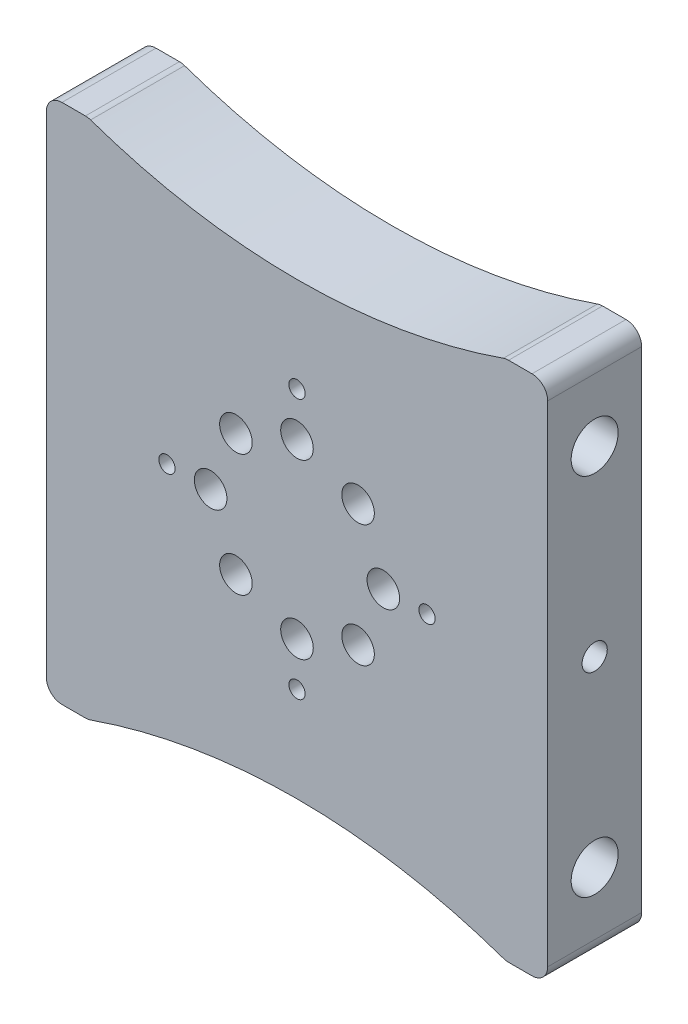
from build123d import *

# Parameters (mm, degrees)
BOSS_EXTRUDE1_DEPTH                 = 19.05
F_1_3_4_CLEARANCE_HOLE1_D           = 45
F_1_3_4_CLEARANCE_HOLE1_DEPTH       = 5
F_1_4_CLEARANCE_HOLE3_D             = 6.6
F_1_4_CLEARANCE_HOLE3_DEPTH         = 19.05
BOSS_EXTRUDE2_DEPTH                 = 19.05
SKETCH21_R                          = 30
CUT_EXTRUDE1_DEPTH                  = 20.05
BOSS_EXTRUDE5_DEPTH                 = 19.05
BOSS_EXTRUDE6_DEPTH                 = 19.05
FILLET2_R                           = 13
SKETCH29_W                          = 12.7
SKETCH29_H                          = 60
BOSS_EXTRUDE7_DEPTH                 = 19.05
BOSS_EXTRUDE8_DEPTH                 = 19.05
FILLET3_R                           = 3.175
F_3_8_0_3750_DOWEL_HOLE1_AT_2_COUNT = 2
F_3_8_0_3750_DOWEL_HOLE1_AT_2_PITCH = 73.92046334
F_4_CLEARANCE_HOLE2_D               = 3.2999934
TAP_DRILL_FOR_1_4_20_TAP1_D         = 5.1054
TAP_DRILL_FOR_1_4_20_TAP1_DEPTH     = 12.7
TAP_DRILL_FOR_1_4_20_TAP1_TIP       = 1.533816902
TAP_DRILL_FOR_1_4_20_TAP2_D         = 5.1054
TAP_DRILL_FOR_1_4_20_TAP2_DEPTH     = 12.7
TAP_DRILL_FOR_1_4_20_TAP2_TIP       = 1.533816902


with BuildPart() as part:
    # Sketch1 → Boss-Extrude1 (new body)
    with BuildSketch(Plane(origin=(0, 0, 0), x_dir=(-1, 0, 0), z_dir=(0, 0, -1))):
        with BuildLine():
            Line((44.45, 0), (44.45, 60))
            Line((44.45, 60), (-44.45, 60))
            Line((-44.45, 60), (-44.45, 0))
            ThreePointArc((-44.45, 0), (0, -44.45), (44.45, 0))
        make_face()
    extrude(amount=-BOSS_EXTRUDE1_DEPTH)

    # 1-3/4 Clearance Hole1
    with Locations(Plane(origin=(0, 0, 0), x_dir=(-1, 0, 0), z_dir=(0, 0, -1))):
        with Locations((-6, 0)):
            Hole(F_1_3_4_CLEARANCE_HOLE1_D / 2, depth=F_1_3_4_CLEARANCE_HOLE1_DEPTH)

    # 1/4 Clearance Hole3
    with Locations(Plane.XY.offset(19.05)):
        with Locations((18.374368671, 12.374368671), (23.499999956, -0.001247108), (18.374368671, -12.374368671), (6, -17.5), (-6.374368671, -12.374368671), (-11.5, 0), (-6.374368671, 12.374368671), (6, 17.5)):
            Hole(F_1_4_CLEARANCE_HOLE3_D / 2, depth=F_1_4_CLEARANCE_HOLE3_DEPTH)

    # Sketch18 → Boss-Extrude2 (add)
    with BuildSketch(Plane(origin=(0, 0, 0), x_dir=(-1, 0, 0), z_dir=(0, 0, -1))):
        with BuildLine():
            Line((-44.45, 0), (-50.45, 0))
            ThreePointArc((-50.45, 0), (-37.430896424, -31.430896424), (-6, -44.45))
            Line((-6, -44.45), (0, -44.45))
            ThreePointArc((0, -44.45), (-31.430896424, -31.430896424), (-44.45, 0))
        make_face()
    extrude(amount=-BOSS_EXTRUDE2_DEPTH)

    # Sketch21 → Cut-Extrude1 (cut, through all)
    with BuildSketch(Plane.XY.offset(19.05)):
        with BuildLine():
            Line((-44.45, 60), (-44.45, 0))
            ThreePointArc((-44.45, 0), (-31.430896424, -31.430896424), (0, -44.45))
            Line((0, -44.45), (6, -44.45))
            ThreePointArc((6, -44.45), (37.430896424, -31.430896424), (50.45, 0))
            Line((50.45, 0), (44.45, 0))
            Line((44.45, 0), (44.45, 60))
            Line((44.45, 60), (-44.45, 60))
        make_face()
        with Locations((5.999999978, -0.000623554)):
            Circle(SKETCH21_R, mode=Mode.SUBTRACT)
    extrude(amount=-CUT_EXTRUDE1_DEPTH, mode=Mode.SUBTRACT)

    # Sketch22 → Boss-Extrude5 (add)
    with BuildSketch(Plane.XY.offset(19.05)):
        with BuildLine():
            Line((44.099999978, -30.000623554), (44.099999978, 29.999376446))
            Line((44.099999978, 29.999376446), (5.999999978, 29.999376446))
            ThreePointArc((5.999999978, 29.999376446), (35.999999978, -0.000623554), (5.999999978, -30.000623554))
            Line((5.999999978, -30.000623554), (44.099999978, -30.000623554))
        make_face()
    boss_extrude5 = extrude(amount=-BOSS_EXTRUDE5_DEPTH)

    # Mirror1: Boss-Extrude5 across plane
    add(boss_extrude5.mirror(Plane(origin=(5.999999978, 0, 0), x_dir=(0, 0, 1), z_dir=(1, 0, 0))))

    # Sketch28 → Boss-Extrude6 (add)
    with BuildSketch(Plane.XY.offset(19.05)):
        with BuildLine():
            Line((-26.798858004, 29.999376446), (38.798858004, 29.999376446))
            ThreePointArc((38.798858004, 29.999376446), (6, 44.448752892), (-26.798858004, 29.999376446))
        make_face()
        with BuildLine():
            ThreePointArc((-26.798858004, -30.000623554), (6, -44.45), (38.798858004, -30.000623554))
            Line((38.798858004, -30.000623554), (-26.798858004, -30.000623554))
        make_face()
    extrude(amount=-BOSS_EXTRUDE6_DEPTH)

    # Fillet2
    fillet2_edges = [part.edges().sort_by_distance(p)[0] for p in [
        (-26.798858004, 29.999376446, 9.525),
        (38.798858004, 29.999376446, 9.525),
        (38.798858004, -30.000623554, 9.525),
        (-26.798858004, -30.000623554, 9.525),
    ]]
    fillet(fillet2_edges, radius=FILLET2_R)

    # Sketch29 → Boss-Extrude7 (add)
    with BuildSketch(Plane.XY):
        with Locations((50.449999978, -0.000623554)):
            Rectangle(SKETCH29_W, SKETCH29_H)
        with Locations((-38.447885426, -0.000623554)):
            Rectangle(SKETCH29_W, SKETCH29_H)
    extrude(amount=BOSS_EXTRUDE7_DEPTH)

    # Sketch40 → Boss-Extrude8 (add)
    with BuildSketch(Plane.XY.offset(19.05)):
        with BuildLine():
            Line((56.799999978, -30.000623554), (44.097885426, -30.000623554))
            ThreePointArc((44.097885426, -30.000623554), (39.487811488, -30.845492198), (35.476953998, -33.27028228))
            ThreePointArc((35.476953998, -33.27028228), (6, -44.45), (-23.476953998, -33.27028228))
            ThreePointArc((-23.476953998, -33.27028228), (-27.487811488, -30.845492198), (-32.097885426, -30.000623554))
            Line((-32.097885426, -30.000623554), (-44.797885426, -30.000623554))
            Line((-44.797885426, -30.000623554), (-44.797885426, -52.835855224))
            Line((-44.797885426, -52.835855224), (-36.33121876, -52.835855224))
            ThreePointArc((-36.33121876, -52.835855224), (6.001057276, -45.572977311), (48.333333311, -52.835855224))
            Line((48.333333311, -52.835855224), (56.799999978, -52.835855224))
            Line((56.799999978, -52.835855224), (56.799999978, -30.000623554))
        make_face()
        with BuildLine():
            Line((-36.33121876, 52.834608116), (-44.797885426, 52.834608116))
            Line((-44.797885426, 52.834608116), (-44.797885426, 29.999376446))
            Line((-44.797885426, 29.999376446), (-32.097885426, 29.999376446))
            ThreePointArc((-32.097885426, 29.999376446), (-27.487811488, 30.84424509), (-23.476953998, 33.269035172))
            ThreePointArc((-23.476953998, 33.269035172), (6, 44.448752892), (35.476953998, 33.269035172))
            ThreePointArc((35.476953998, 33.269035172), (39.487811488, 30.84424509), (44.097885426, 29.999376446))
            Line((44.097885426, 29.999376446), (56.799999978, 29.999376446))
            Line((56.799999978, 29.999376446), (56.799999978, 52.834608116))
            Line((56.799999978, 52.834608116), (48.333333311, 52.834608116))
            ThreePointArc((48.333333311, 52.834608116), (6.001057276, 45.571730203), (-36.33121876, 52.834608116))
        make_face()
    extrude(amount=-BOSS_EXTRUDE8_DEPTH)

    # Fillet3
    fillet3_edges = [part.edges().sort_by_distance(p)[0] for p in [
        (-44.797885426, -52.835855224, 9.525),
        (-36.33121876, -52.835855224, 9.525),
        (48.333333311, -52.835855224, 9.525),
        (56.799999978, -52.835855224, 9.525),
        (56.799999978, 52.834608116, 9.525),
        (48.333333311, 52.834608116, 9.525),
        (-36.33121876, 52.834608116, 9.525),
        (-44.797885426, 52.834608116, 9.525),
    ]]
    fillet(fillet3_edges, radius=FILLET3_R)

    # Sketch49 → 3/8 (0.3750) Dowel Hole1 (revolve, cut)
    with BuildSketch(Plane(origin=(56.799999978, -36.960855224, 9.525), x_dir=(0, 0, -1), z_dir=(0, 1, 0))):
        Polygon((0, 0), (0, 28.261598698), (4.7625, 25.4), (4.7625, 0), align=None)
    f_3_8_0_3750_dowel_hole1 = revolve(axis=Axis((63.149999978, -36.960855224, 9.525), (-1, 0, 0)), mode=Mode.SUBTRACT)

    # 3/8 (0.3750) Dowel Hole1 at 2: 3/8 (0.3750) Dowel Hole1 ×2
    with Locations(*[(0, i * F_3_8_0_3750_DOWEL_HOLE1_AT_2_PITCH, 0) for i in range(1, F_3_8_0_3750_DOWEL_HOLE1_AT_2_COUNT)]):
        add(f_3_8_0_3750_dowel_hole1, mode=Mode.SUBTRACT)

    # Mirror6: 3/8 (0.3750) Dowel Hole1 across plane
    add(f_3_8_0_3750_dowel_hole1.mirror(Plane(origin=(5.999999978, 0, 0), x_dir=(0, 0, 1), z_dir=(1, 0, 0))), mode=Mode.SUBTRACT)

    # Mirror6 copy 1 sketch → Mirror6 copy 1 (revolve, cut)
    with BuildSketch(Plane(origin=(-44.800000022, 36.959608116, 9.525), x_dir=(0, 0, -1), z_dir=(0, 1, 0))):
        Polygon((0, 0), (0, -28.261598698), (4.7625, -25.4), (4.7625, 0), align=None)
    revolve(axis=Axis((-51.150000022, 36.959608116, 9.525), (-1, 0, 0)), mode=Mode.SUBTRACT)

    # #4 Clearance Hole2 (through all)
    with Locations(Plane(origin=(0, 0, 0), x_dir=(-1, 0, 0), z_dir=(0, 0, -1))):
        with Locations((-6, -26.35), (20.35, 0), (-6, 26.35), (-32.35, 0)):
            Hole(F_4_CLEARANCE_HOLE2_D / 2)

    # Tap Drill for 1/4-20 Tap1
    with Locations(Plane.ZY.offset(44.797885426)):
        with Locations((9.525, -0.000623554)):
            Hole(TAP_DRILL_FOR_1_4_20_TAP1_D / 2, depth=TAP_DRILL_FOR_1_4_20_TAP1_DEPTH)
            with Locations((0, 0, -(TAP_DRILL_FOR_1_4_20_TAP1_DEPTH + TAP_DRILL_FOR_1_4_20_TAP1_TIP / 2))):  # 118° drill point
                Cone(0, TAP_DRILL_FOR_1_4_20_TAP1_D / 2, TAP_DRILL_FOR_1_4_20_TAP1_TIP, mode=Mode.SUBTRACT)

    # Tap Drill for 1/4-20 Tap2
    with Locations(Plane(origin=(56.799999978, 0, 0), x_dir=(0, 0, -1), z_dir=(1, 0, 0))):
        with Locations((-9.525, -0.000623554)):
            Hole(TAP_DRILL_FOR_1_4_20_TAP2_D / 2, depth=TAP_DRILL_FOR_1_4_20_TAP2_DEPTH)
            with Locations((0, 0, -(TAP_DRILL_FOR_1_4_20_TAP2_DEPTH + TAP_DRILL_FOR_1_4_20_TAP2_TIP / 2))):  # 118° drill point
                Cone(0, TAP_DRILL_FOR_1_4_20_TAP2_D / 2, TAP_DRILL_FOR_1_4_20_TAP2_TIP, mode=Mode.SUBTRACT)


solid = part.part
